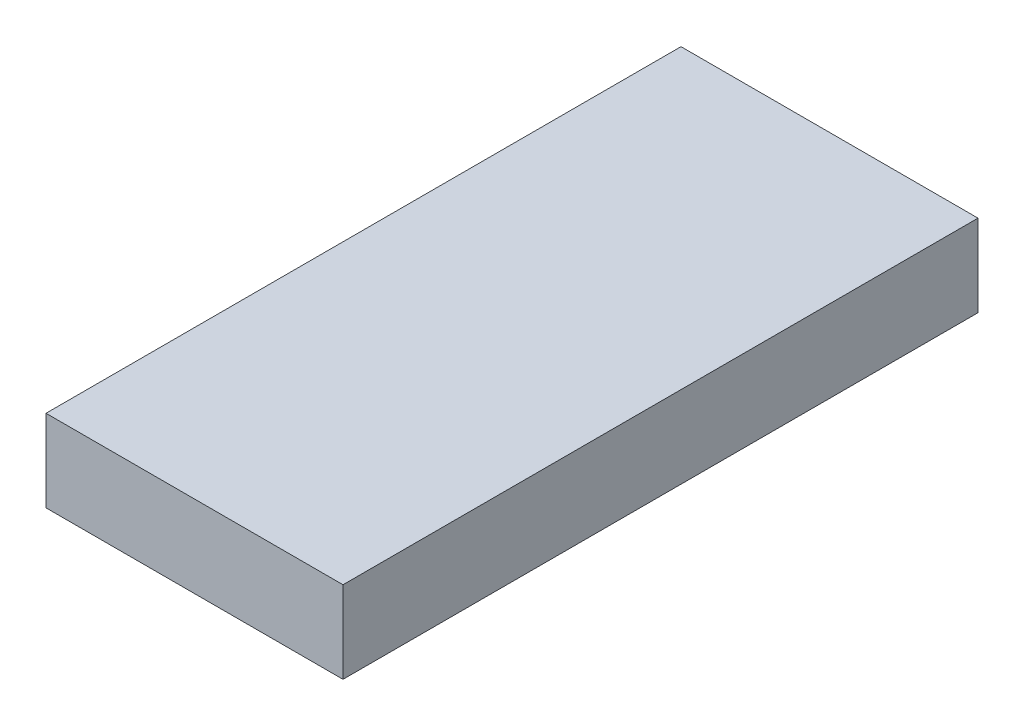
from build123d import *

# Parameters (mm, degrees)
SKETCH1_W           = 73.66
SKETCH1_H           = 157.48
BOSS_EXTRUDE1_DEPTH = 20.32


with BuildPart() as part:
    # Sketch1 → Boss-Extrude1 (new body)
    with BuildSketch(Plane(origin=(0, 0, 0), x_dir=(1, 0, 0), z_dir=(0, 1, 0))):
        with Locations((36.83, 78.74)):
            Rectangle(SKETCH1_W, SKETCH1_H)
    extrude(amount=BOSS_EXTRUDE1_DEPTH)


solid = part.part
